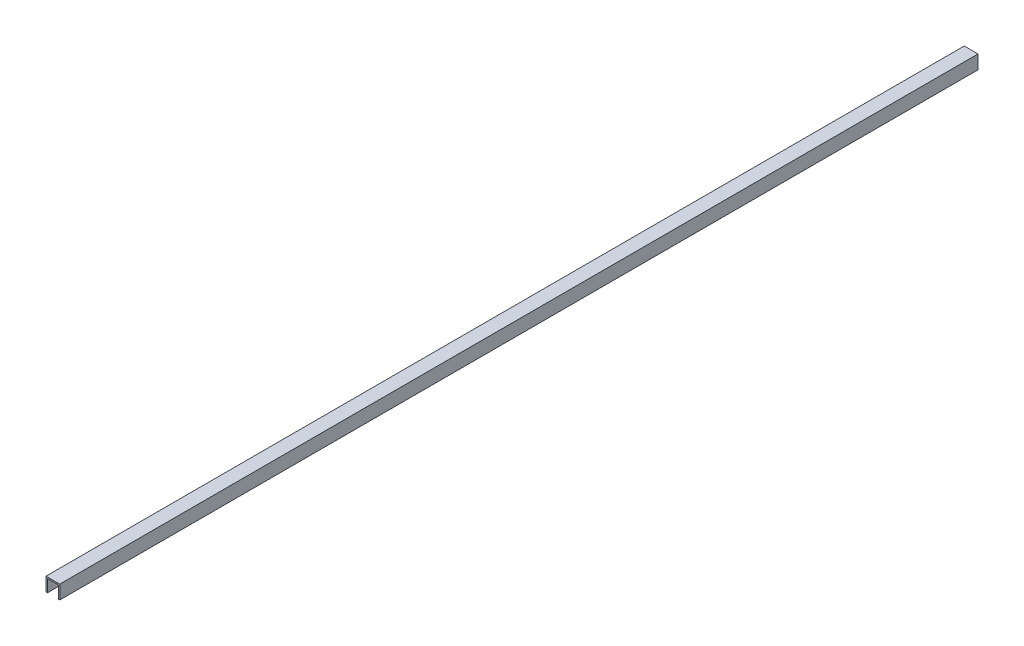
from build123d import *

# Parameters (mm, degrees)
BOSS_EXTRUDE1_DEPTH = 500


with BuildPart() as part:
    # Sketch2 → Boss-Extrude1 (new body, symmetric)
    with BuildSketch(Plane.XY):
        Polygon((-6, -7.5), (-6, 6), (6, 6), (6, -7.5), (7.5, -7.5), (7.5, 7.5), (-7.5, 7.5), (-7.5, -7.5), align=None)
    extrude(amount=BOSS_EXTRUDE1_DEPTH, both=True)


solid = part.part
